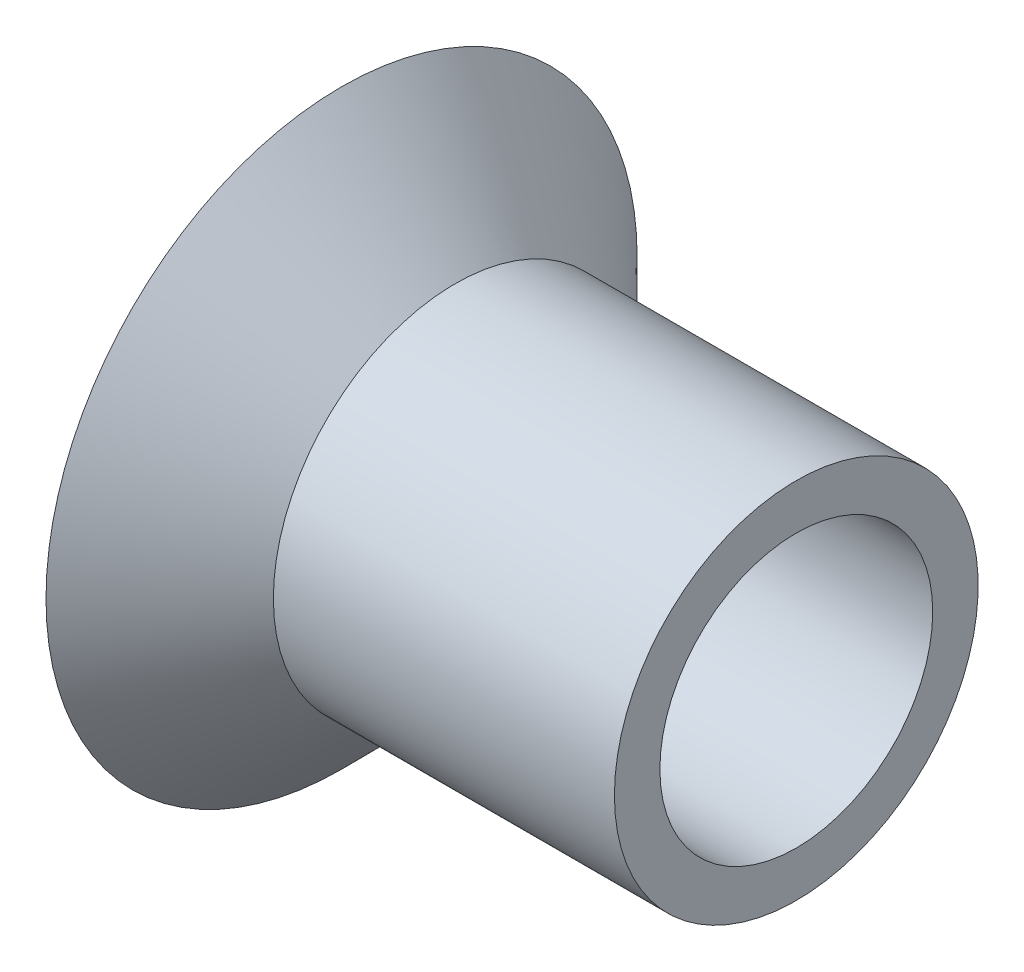
from build123d import *


with BuildPart() as part:
    # Sketch1 → Revolve1 (revolve)
    with BuildSketch(Plane.XY):
        Polygon((5, 4), (-2.5, 4), (-5, 6.5), (-5, 5.085786438), (-2.914213562, 3), (5, 3), align=None)
    revolve(axis=Axis((-9.579622459, 0, 0), (1, 0, 0)))


solid = part.part
